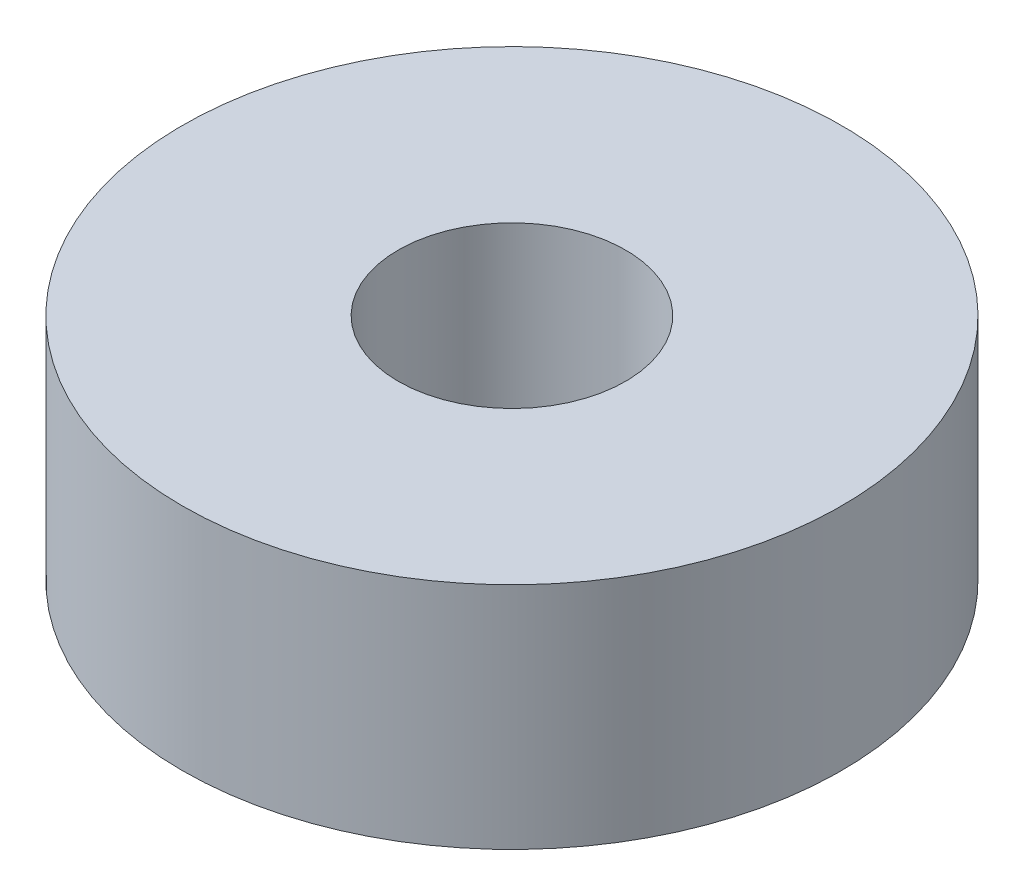
from build123d import *

# Parameters (mm, degrees)
SKETCH1_R           = 11.5
SKETCH1_R_2         = 3.96875
BOSS_EXTRUDE1_DEPTH = 8


with BuildPart() as part:
    # Sketch1 → Boss-Extrude1 (new body)
    with BuildSketch(Plane(origin=(0, 0, 0), x_dir=(1, 0, 0), z_dir=(0, 1, 0))):
        Circle(SKETCH1_R)
        Circle(SKETCH1_R_2, mode=Mode.SUBTRACT)
    extrude(amount=BOSS_EXTRUDE1_DEPTH)


solid = part.part
